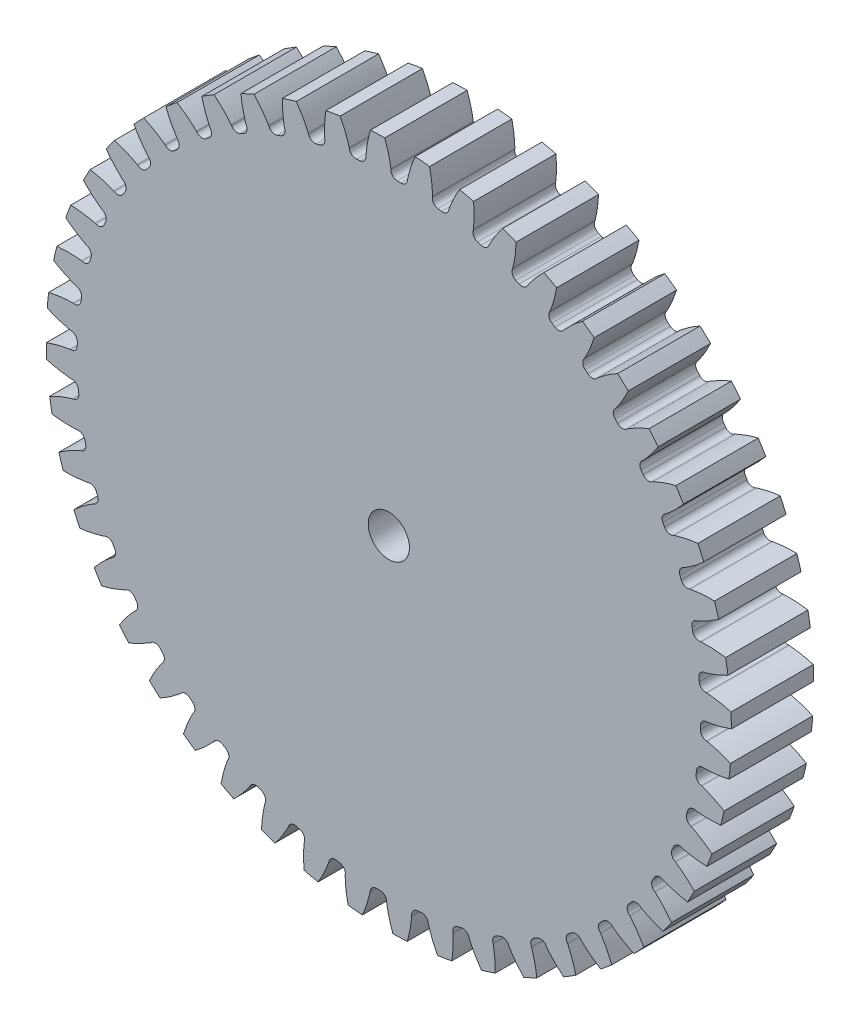
from build123d import *

# Parameters (mm, degrees)
SKETCH1_R                = 26.416
BOSS_EXTRUDE1_DEPTH      = 6.35
CUT_EXTRUDE1_DEPTH       = 7.35
FILLET1_R                = 0.498729
CIRPATTERN1_COUNT        = 48
FILLET1_OF_CIRPATTERN1_R = 0.498729
SKETCH5_R                = 1.5875
CUT_EXTRUDE2_DEPTH       = 7.3500007


with BuildPart() as part:
    # Sketch1 → Boss-Extrude1 (new body)
    with BuildSketch(Plane.XY):
        Circle(SKETCH1_R)
    extrude(amount=-BOSS_EXTRUDE1_DEPTH)

    # Sketch4 → Cut-Extrude1 (cut, through all)
    with BuildSketch(Plane.XY):
        with BuildLine():
            Line((0.159954842, 24.590429837), (0.159954842, 24.034217732))
            ThreePointArc((0.159954842, 24.034217732), (0.786396814, 24.021881434), (1.412304354, 23.993219958))
            Line((1.412304354, 23.993219958), (1.448682451, 24.548241165))
            add(Edge.make_bspline(
                [(4.459276505, 29.644617695), (2.090539262, 27.458064028), (1.448682451, 24.548241165)],
                knots=[0, 0, 0, 1, 1, 1], degree=2))
            ThreePointArc((4.459276505, 29.644617695), (0.980859335, 29.962083041), (-2.510873518, 29.872797314))
            add(Edge.make_bspline(
                [(-2.510873518, 29.872797314), (-0.290215733, 27.536002059), (0.159954842, 24.590429837)],
                knots=[0, 0, 0, 1, 1, 1], degree=2))
        make_face()
    cut_extrude1 = extrude(amount=-CUT_EXTRUDE1_DEPTH, mode=Mode.SUBTRACT)

    # Fillet1
    fillet1_edges = [part.edges().sort_by_distance(p)[0] for p in [
        (1.412304354, 23.993219958, -3.175),
        (0.159954842, 24.034217732, -3.175),
    ]]
    fillet(fillet1_edges, radius=FILLET1_R)

    # CirPattern1: Cut-Extrude1 ×48 about axis
    cirpattern1_axis = Axis((0, 0, -6.35), (0, 0, 1))
    for i in range(1, CIRPATTERN1_COUNT):
        add(cut_extrude1.rotate(cirpattern1_axis, i * 360 / CIRPATTERN1_COUNT), mode=Mode.SUBTRACT)

    # Fillet1 of CirPattern1
    fillet1_of_cirpattern1_edges = [part.edges().sort_by_distance(p)[0] for p in [
        (-1.731521746, 23.972297345, -3.175),
        (-2.978508517, 23.849479964, -3.175),
        (-4.845721029, 23.541202078, -3.175),
        (-6.06600877, 23.256670982, -3.175),
        (-7.877008681, 22.707310316, -3.175),
        (-9.049717931, 22.265933911, -3.175),
        (-10.773518531, 21.484890179, -3.175),
        (-11.878583909, 20.894220538, -3.175),
        (-13.485690492, 19.894857615, -3.175),
        (-14.504204023, 19.165001258, -3.175),
        (-15.967118549, 17.964418521, -3.175),
        (-16.881653185, 17.107863493, -3.175),
        (-18.175344782, 15.726603245, -3.175),
        (-18.970252581, 14.75800544, -3.175),
        (-20.072585826, 13.219701427, -3.175),
        (-20.734265695, 12.155633823, -3.175),
        (-21.626379361, 10.486606853, -3.175),
        (-22.143509775, 9.345275941, -3.175),
        (-22.810139549, 7.574083528, -3.175),
        (-23.173872263, 6.375017797, -3.175),
        (-23.603611926, 4.531965535, -3.175),
        (-23.807723371, 3.29568133, -3.175),
        (-23.993219958, 1.412304354, -3.175),
        (-24.034217732, 0.159954842, -3.175),
        (-23.972297345, -1.731521746, -3.175),
        (-23.849479964, -2.978508517, -3.175),
        (-23.541202078, -4.845721029, -3.175),
        (-23.256670982, -6.06600877, -3.175),
        (-22.707310316, -7.877008681, -3.175),
        (-22.265933911, -9.049717931, -3.175),
        (-21.484890179, -10.773518531, -3.175),
        (-20.894220538, -11.878583909, -3.175),
        (-19.894857615, -13.485690492, -3.175),
        (-19.165001258, -14.504204023, -3.175),
        (-17.964418521, -15.967118549, -3.175),
        (-17.107863493, -16.881653185, -3.175),
        (-15.726603245, -18.175344782, -3.175),
        (-14.75800544, -18.970252581, -3.175),
        (-13.219701427, -20.072585826, -3.175),
        (-12.155633823, -20.734265695, -3.175),
        (-10.486606853, -21.626379361, -3.175),
        (-9.345275941, -22.143509775, -3.175),
        (-7.574083528, -22.810139549, -3.175),
        (-6.375017797, -23.173872263, -3.175),
        (-4.531965535, -23.603611926, -3.175),
        (-3.29568133, -23.807723371, -3.175),
        (-1.412304354, -23.993219958, -3.175),
        (-0.159954842, -24.034217732, -3.175),
        (1.731521746, -23.972297345, -3.175),
        (2.978508517, -23.849479964, -3.175),
        (4.845721029, -23.541202078, -3.175),
        (6.06600877, -23.256670982, -3.175),
        (7.877008681, -22.707310316, -3.175),
        (9.049717931, -22.265933911, -3.175),
        (10.773518531, -21.484890179, -3.175),
        (11.878583909, -20.894220538, -3.175),
        (13.485690492, -19.894857615, -3.175),
        (14.504204023, -19.165001258, -3.175),
        (15.967118549, -17.964418521, -3.175),
        (16.881653185, -17.107863493, -3.175),
        (18.175344782, -15.726603245, -3.175),
        (18.970252581, -14.75800544, -3.175),
        (20.072585826, -13.219701427, -3.175),
        (20.734265695, -12.155633823, -3.175),
        (21.626379361, -10.486606853, -3.175),
        (22.143509775, -9.345275941, -3.175),
        (22.810139549, -7.574083528, -3.175),
        (23.173872263, -6.375017797, -3.175),
        (23.603611926, -4.531965535, -3.175),
        (23.807723371, -3.29568133, -3.175),
        (23.993219958, -1.412304354, -3.175),
        (24.034217732, -0.159954842, -3.175),
        (23.972297345, 1.731521746, -3.175),
        (23.849479964, 2.978508517, -3.175),
        (23.541202078, 4.845721029, -3.175),
        (23.256670982, 6.06600877, -3.175),
        (22.707310316, 7.877008681, -3.175),
        (22.265933911, 9.049717931, -3.175),
        (21.484890179, 10.773518531, -3.175),
        (20.894220538, 11.878583909, -3.175),
        (19.894857615, 13.485690492, -3.175),
        (19.165001258, 14.504204023, -3.175),
        (17.964418521, 15.967118549, -3.175),
        (17.107863493, 16.881653185, -3.175),
        (15.726603245, 18.175344782, -3.175),
        (14.75800544, 18.970252581, -3.175),
        (13.219701427, 20.072585826, -3.175),
        (12.155633823, 20.734265695, -3.175),
        (10.486606853, 21.626379361, -3.175),
        (9.345275941, 22.143509775, -3.175),
        (7.574083528, 22.810139549, -3.175),
        (6.375017797, 23.173872263, -3.175),
        (4.531965535, 23.603611926, -3.175),
        (3.29568133, 23.807723371, -3.175),
    ]]
    fillet(fillet1_of_cirpattern1_edges, radius=FILLET1_OF_CIRPATTERN1_R)

    # Sketch5 → Cut-Extrude2 (cut, through all)
    with BuildSketch(Plane.XY):
        Circle(SKETCH5_R)
    extrude(amount=-CUT_EXTRUDE2_DEPTH, mode=Mode.SUBTRACT)


solid = part.part
